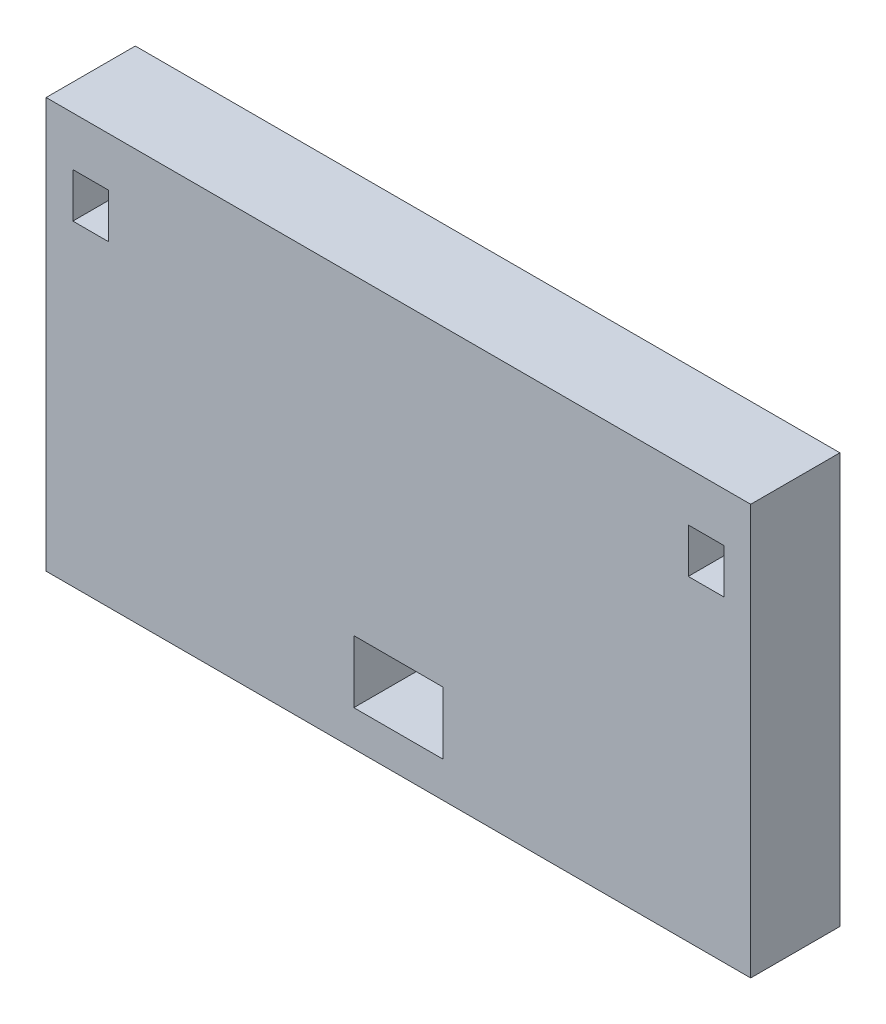
from build123d import *

# Parameters (mm, degrees)
SKETCH1_W           = 79
SKETCH1_H           = 46
SKETCH1_W_2         = 10
SKETCH1_H_2         = 7
SKETCH1_W_3         = 4
SKETCH1_H_3         = 5
BOSS_EXTRUDE1_DEPTH = 10


with BuildPart() as part:
    # Sketch1 → Boss-Extrude1 (new body)
    with BuildSketch(Plane.XY):
        with Locations((0, 20.611542264)):
            Rectangle(SKETCH1_W, SKETCH1_H)
        Polygon((-32.5, 38.111542264), (-36.5, 38.111542264), (-36.5, 33.111542264), (-32.5, 33.107370015), align=None, mode=Mode.SUBTRACT)
        with Locations((0, 5.111542264)):
            Rectangle(SKETCH1_W_2, SKETCH1_H_2, mode=Mode.SUBTRACT)
        with Locations((34.5, 35.607370015)):
            Rectangle(SKETCH1_W_3, SKETCH1_H_3, mode=Mode.SUBTRACT)
    extrude(amount=BOSS_EXTRUDE1_DEPTH)


solid = part.part
